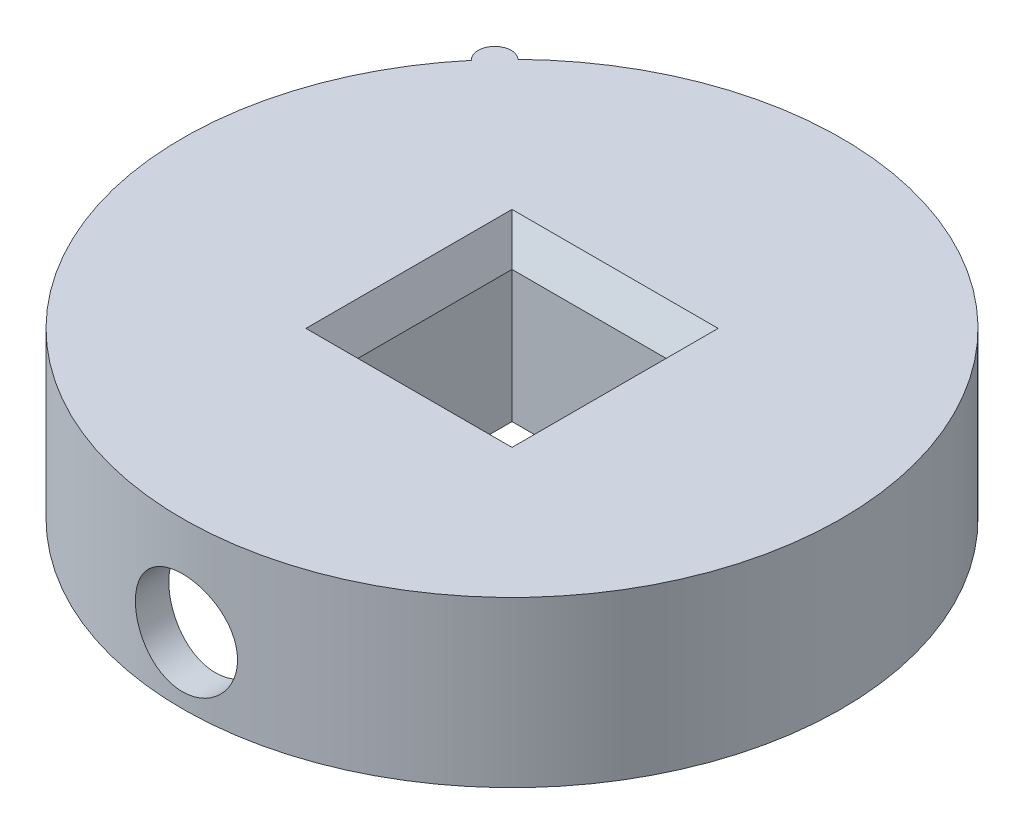
from build123d import *

# Parameters (mm, degrees)
SKETCH1_R             = 20
BOSS_EXTRUDE1_DEPTH   = 10
SKETCH2_W             = 10.2
SKETCH2_H             = 10.2
CUT_EXTRUDE2_DEPTH    = 11
SHELL3_T              = -2
SKETCH3_R             = 3.1
CUT_EXTRUDE3_DEPTH    = 13.9
BOSS_EXTRUDE2_DEPTH   = 10
CHAMFER1_SIZE         = 2
CHAMFER1_SIZE2        = 1.154700538
CHAMFER1_PART_2_SIZE  = 2
CHAMFER1_PART_2_SIZE2 = 1.154700538
CHAMFER1_PART_3_SIZE  = 2
CHAMFER1_PART_3_SIZE2 = 1.154700538
CHAMFER1_PART_4_SIZE  = 2
CHAMFER1_PART_4_SIZE2 = 1.154700538


with BuildPart() as part:
    # Sketch1 → Boss-Extrude1 (new body)
    with BuildSketch(Plane(origin=(0, 0, 0), x_dir=(1, 0, 0), z_dir=(0, 1, 0))):
        Circle(SKETCH1_R)
    extrude(amount=BOSS_EXTRUDE1_DEPTH)

    # Sketch2 → Cut-Extrude2 (cut, through all)
    with BuildSketch(Plane.XZ):
        Rectangle(SKETCH2_W, SKETCH2_H)
    extrude(amount=-CUT_EXTRUDE2_DEPTH, mode=Mode.SUBTRACT)

    # Shell3
    shell3_openings = [part.faces().sort_by_distance(p)[0] for p in [
        (0, 0, 0),
    ]]
    offset(amount=SHELL3_T, openings=shell3_openings, kind=Kind.INTERSECTION)

    # Sketch3 → Cut-Extrude3 (cut, through all)
    with BuildSketch(Plane.XY.offset(7.1)):
        with Locations((0, 4)):
            Circle(SKETCH3_R)
    extrude(amount=CUT_EXTRUDE3_DEPTH, mode=Mode.SUBTRACT)

    # Sketch4 → Boss-Extrude2 (add)
    with BuildSketch(Plane(origin=(0, 10, 0), x_dir=(1, 0, 0), z_dir=(0, 1, 0))):
        with BuildLine():
            Line((-13.960317173, 14.321646009), (-15.320888862, 12.855752194))
            ThreePointArc((-15.320888862, 12.855752194), (-15.373549926, 14.268984946), (-13.960317173, 14.321646009))
        make_face()
    extrude(amount=-BOSS_EXTRUDE2_DEPTH)

    # Chamfer1
    chamfer1_edges = [part.edges().sort_by_distance(p)[0] for p in [
        (5.1, 10, 0),
    ]]
    chamfer1_side = [part.faces().sort_by_distance(p)[0] for p in [
        (5.1, 5, 0),
    ]]
    chamfer(chamfer1_edges, length=CHAMFER1_SIZE, length2=CHAMFER1_SIZE2, reference=chamfer1_side[0])

    # Chamfer1 part 2
    chamfer1_part_2_edges = [part.edges().sort_by_distance(p)[0] for p in [
        (0, 10, -5.1),
    ]]
    chamfer1_part_2_side = [part.faces().sort_by_distance(p)[0] for p in [
        (0, 5, -5.1),
    ]]
    chamfer(chamfer1_part_2_edges, length=CHAMFER1_PART_2_SIZE, length2=CHAMFER1_PART_2_SIZE2, reference=chamfer1_part_2_side[0])

    # Chamfer1 part 3
    chamfer1_part_3_edges = [part.edges().sort_by_distance(p)[0] for p in [
        (-5.1, 10, 0),
    ]]
    chamfer1_part_3_side = [part.faces().sort_by_distance(p)[0] for p in [
        (-5.1, 5, 0),
    ]]
    chamfer(chamfer1_part_3_edges, length=CHAMFER1_PART_3_SIZE, length2=CHAMFER1_PART_3_SIZE2, reference=chamfer1_part_3_side[0])

    # Chamfer1 part 4
    chamfer1_part_4_edges = [part.edges().sort_by_distance(p)[0] for p in [
        (0, 10, 5.1),
    ]]
    chamfer1_part_4_side = [part.faces().sort_by_distance(p)[0] for p in [
        (0, 5, 5.1),
    ]]
    chamfer(chamfer1_part_4_edges, length=CHAMFER1_PART_4_SIZE, length2=CHAMFER1_PART_4_SIZE2, reference=chamfer1_part_4_side[0])


solid = part.part
